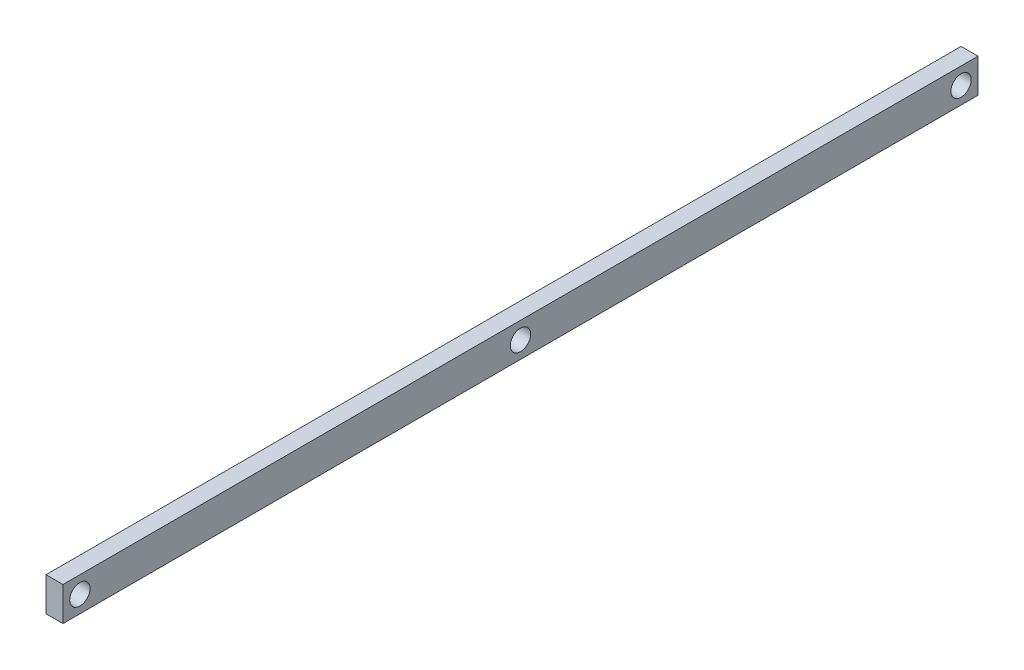
from build123d import *

# Parameters (mm, degrees)
SKETCH1_W           = 270
SKETCH1_H           = 10
BOSS_EXTRUDE1_DEPTH = 5
SKETCH2_R           = 3
CUT_EXTRUDE1_DEPTH  = 5


with BuildPart() as part:
    # Sketch1 → Boss-Extrude1 (new body)
    with BuildSketch(Plane(origin=(0, 0, 0), x_dir=(0, 0, -1), z_dir=(1, 0, 0))):
        Rectangle(SKETCH1_W, SKETCH1_H)
    extrude(amount=BOSS_EXTRUDE1_DEPTH)

    # Sketch2 → Cut-Extrude1 (cut)
    with BuildSketch(Plane(origin=(5, 0, 0), x_dir=(0, 0, -1), z_dir=(1, 0, 0))):
        Circle(SKETCH2_R)
        with Locations((130, 0)):
            Circle(SKETCH2_R)
        with Locations((-130, 0)):
            Circle(SKETCH2_R)
    extrude(amount=-CUT_EXTRUDE1_DEPTH, mode=Mode.SUBTRACT)


solid = part.part
